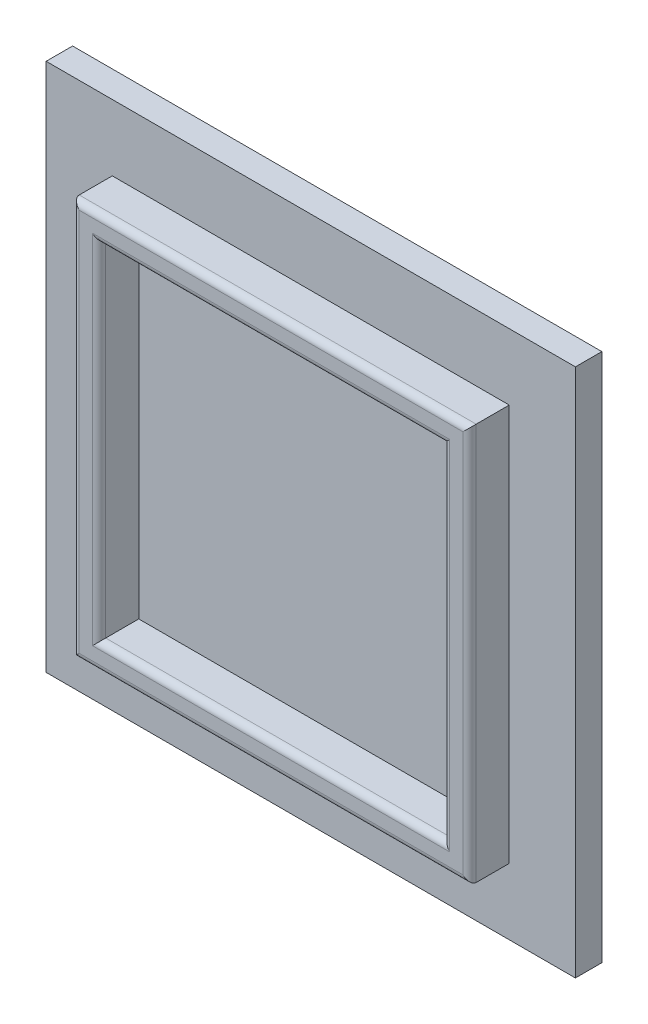
from build123d import *

# Parameters (mm, degrees)
SKETCH1_W           = 40
SKETCH1_H           = 40
BOSS_EXTRUDE1_DEPTH = 2
SKETCH2_W           = 30
SKETCH2_H           = 30
SKETCH2_W_2         = 26
SKETCH2_H_2         = 26
BOSS_EXTRUDE2_DEPTH = 3
FILLET1_R           = 0.5


with BuildPart() as part:
    # Sketch1 → Boss-Extrude1 (new body)
    with BuildSketch(Plane.XY):
        with Locations((-5.192307692, -4.855769231)):
            Rectangle(SKETCH1_W, SKETCH1_H)
    extrude(amount=BOSS_EXTRUDE1_DEPTH)

    # Sketch2 → Boss-Extrude2 (add)
    with BuildSketch(Plane.XY.offset(2)):
        with Locations((-5.192307692, -4.855769231)):
            Rectangle(SKETCH2_W, SKETCH2_H)
        with Locations((-5.192307692, -4.855769231)):
            Rectangle(SKETCH2_W_2, SKETCH2_H_2, mode=Mode.SUBTRACT)
    extrude(amount=BOSS_EXTRUDE2_DEPTH)

    # Fillet1
    fillet1_edges = [part.edges().sort_by_distance(p)[0] for p in [
        (-20.192307692, -4.855769231, 5),
        (-5.192307692, -19.855769231, 5),
        (9.807692308, -4.855769231, 5),
        (-5.192307692, 10.144230769, 5),
        (-18.192307692, -4.855769231, 5),
        (-5.192307692, -17.855769231, 5),
        (7.807692308, -4.855769231, 5),
        (-5.192307692, 8.144230769, 5),
    ]]
    fillet(fillet1_edges, radius=FILLET1_R)


solid = part.part
